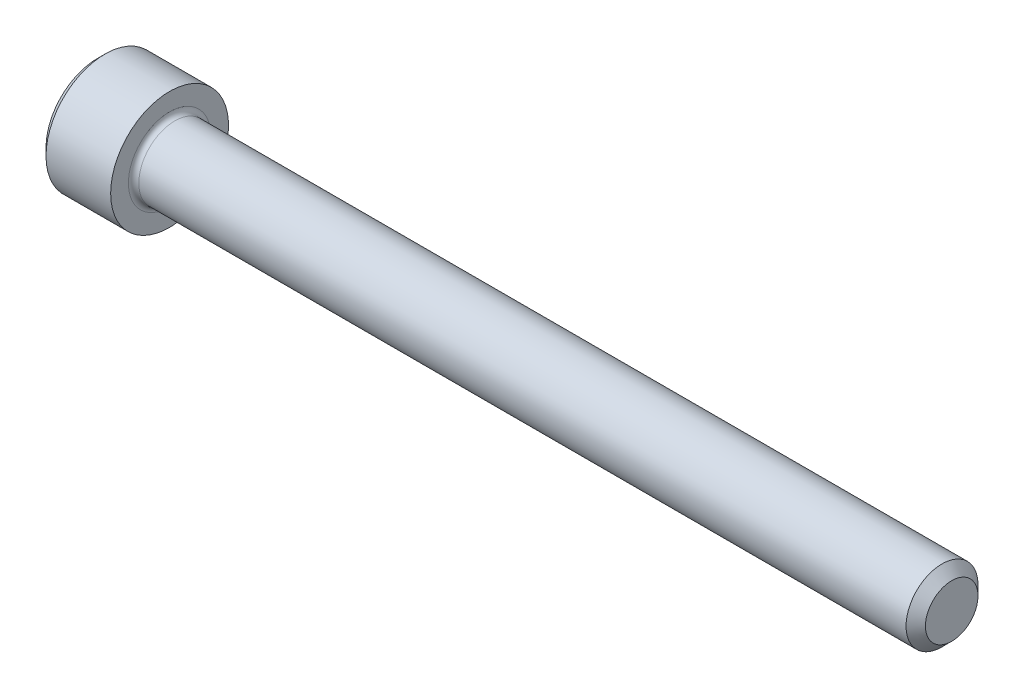
from build123d import *

# Parameters (mm, degrees)
FILLET1_R   = 0.254
HEX_2_DEPTH = 1.6256


with BuildPart() as part:
    # BodySke → Base-Revolve (revolve)
    with BuildSketch(Plane.XY):
        Polygon((0, 0), (0, 2.5146), (0.3556, 2.8702), (3.5052, 2.8702), (3.5052, 1.7526), (41.13276, 1.7526), (41.6052, 1.28016), (41.6052, 0), align=None)
    revolve(axis=Axis((-31.75, 0, 0), (1, 0, 0)))

    # Fillet1
    fillet1_edges = [part.edges().sort_by_distance(p)[0] for p in [
        (3.5052, -1.7526, 0),
    ]]
    fillet(fillet1_edges, radius=FILLET1_R)

    # Sketch2 → Hex-PreBroach (revolve, cut)
    with BuildSketch(Plane.XY):
        Polygon((0, 1.3843), (1.6256, 1.3843), (2.424825978, 0), (0, 0), align=None)
    revolve(axis=Axis((0, 0, 0), (1, 0, 0)), mode=Mode.SUBTRACT)

    # Sketch3 → Hex 2 (cut)
    with BuildSketch(Plane(origin=(0, 0, 0), x_dir=(0, 0.5, 0.866025404), z_dir=(-1, 0, 0))):
        Polygon((0.799225978, 1.3843), (-0.799225978, 1.3843), (-1.598451955, 0), (-0.799225978, -1.3843), (0.799225978, -1.3843), (1.598451955, 0), align=None)
    extrude(amount=-HEX_2_DEPTH, mode=Mode.SUBTRACT)


solid = part.part
